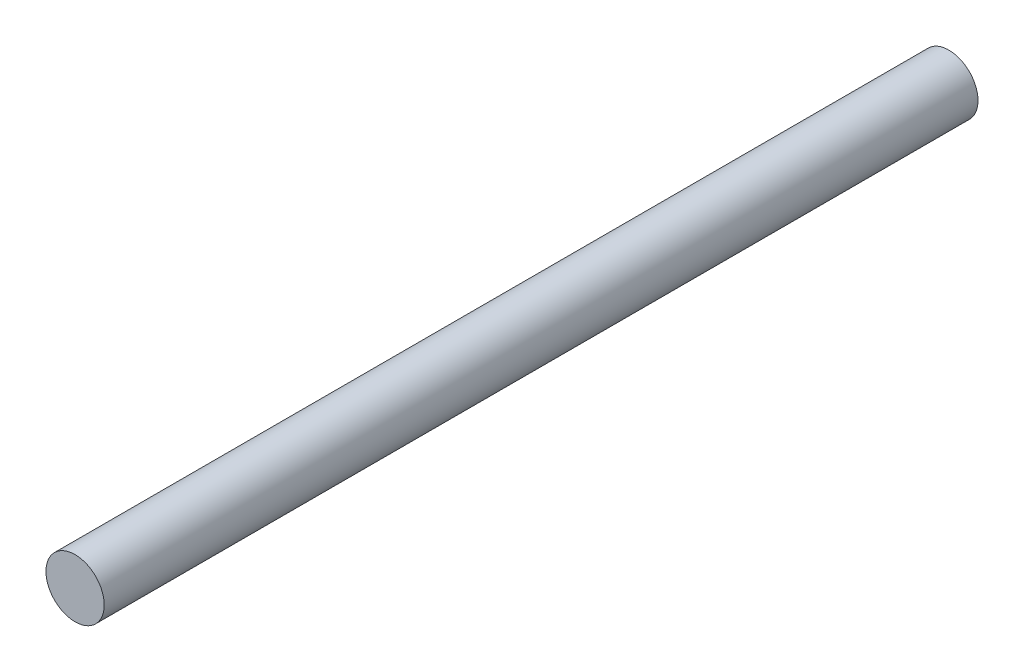
from build123d import *

# Parameters (mm, degrees)
CROQUIS1_R              = 10
SALIENTE_EXTRUIR1_DEPTH = 300


with BuildPart() as part:
    # Croquis1 → Saliente-Extruir1 (new body)
    with BuildSketch(Plane.XY):
        Circle(CROQUIS1_R)
    extrude(amount=SALIENTE_EXTRUIR1_DEPTH)


solid = part.part
